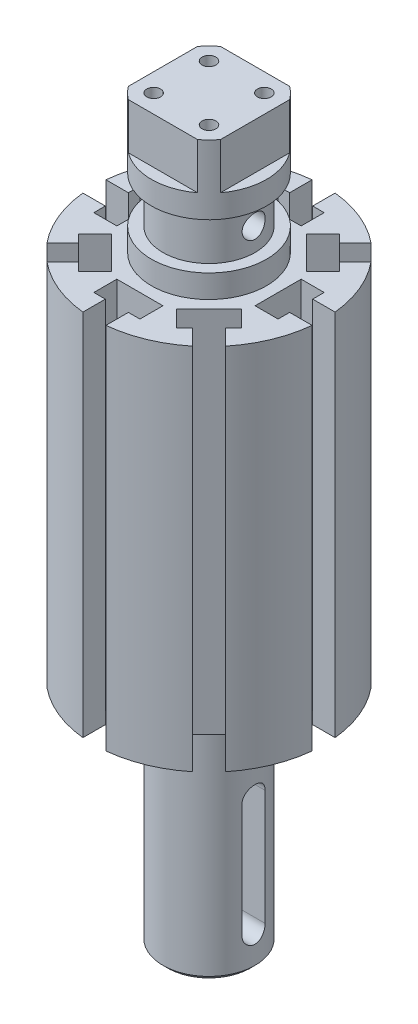
from build123d import *

# Parameters (mm, degrees)
CHAMFER1_SIZE       = 1
CUT_EXTRUDE6_DEPTH  = 130
CIRPATTERN1_COUNT   = 8
CUT_EXTRUDE8_DEPTH  = 10
SKETCH4_R           = 1.5
CUT_EXTRUDE9_DEPTH  = 15
SKETCH5_R           = 2.5
CUT_EXTRUDE10_DEPTH = 20
CUT_EXTRUDE11_DEPTH = 20


with BuildPart() as part:
    # Sketch1 → Revolve8 (revolve)
    with BuildSketch(Plane.XY):
        Polygon((0, 0), (10, 0), (10, 50), (25, 50), (25, 130), (12.5, 130), (12.5, 135), (10, 135), (10, 145), (12.5, 145), (12.5, 160), (0, 160), align=None)
    revolve(axis=Axis((0, 0, 0), (0, 1, 0)))

    # Chamfer1
    chamfer1_edges = [part.edges().sort_by_distance(p)[0] for p in [
        (-10, 0, 0),
    ]]
    chamfer(chamfer1_edges, length=CHAMFER1_SIZE)

    # Sketch2 → Cut-Extrude6 (cut)
    with BuildSketch(Plane(origin=(0, 0, 0), x_dir=(1, 0, 0), z_dir=(0, 1, 0))):
        with BuildLine():
            Line((24.874685928, 2.5), (20, 2.5))
            Line((20, 2.5), (20, 5))
            Line((20, 5), (15, 5))
            Line((15, 5), (15, -5))
            Line((15, -5), (20, -5))
            Line((20, -5), (20, -2.5))
            Line((20, -2.5), (24.874685928, -2.5))
            ThreePointArc((24.874685928, -2.5), (25, 0), (24.874685928, 2.5))
        make_face()
    cut_extrude6 = extrude(amount=CUT_EXTRUDE6_DEPTH, mode=Mode.SUBTRACT)

    # CirPattern1: Cut-Extrude6 ×8 about axis
    cirpattern1_axis = Axis((0, 0, 0), (0, 1, 0))
    for i in range(1, CIRPATTERN1_COUNT):
        add(cut_extrude6.rotate(cirpattern1_axis, i * 360 / CIRPATTERN1_COUNT), mode=Mode.SUBTRACT)

    # Sketch3 → Cut-Extrude8 (cut)
    with BuildSketch(Plane(origin=(0, 160, 0), x_dir=(1, 0, 0), z_dir=(0, 1, 0))):
        with BuildLine():
            Line((-7.5, 10), (7.5, 10))
            ThreePointArc((7.5, 10), (0, 12.5), (-7.5, 10))
        make_face()
        with BuildLine():
            Line((-10, 7.5), (-10, -7.5))
            ThreePointArc((-10, -7.5), (-12.5, 0), (-10, 7.5))
        make_face()
        with BuildLine():
            Line((-7.5, -10), (7.5, -10))
            ThreePointArc((7.5, -10), (0, -12.5), (-7.5, -10))
        make_face()
        with BuildLine():
            Line((10, 7.5), (10, -7.5))
            ThreePointArc((10, -7.5), (12.5, 0), (10, 7.5))
        make_face()
    extrude(amount=-CUT_EXTRUDE8_DEPTH, mode=Mode.SUBTRACT)

    # Sketch4 → Cut-Extrude9 (cut)
    with BuildSketch(Plane(origin=(0, 160, 0), x_dir=(1, 0, 0), z_dir=(0, 1, 0))):
        with Locations((-6, 6)):
            Circle(SKETCH4_R)
        with Locations((6, 6)):
            Circle(SKETCH4_R)
        with Locations((6, -6)):
            Circle(SKETCH4_R)
        with Locations((-6, -6)):
            Circle(SKETCH4_R)
    extrude(amount=-CUT_EXTRUDE9_DEPTH, mode=Mode.SUBTRACT)

    # Sketch5 → Cut-Extrude10 (cut)
    with BuildSketch(Plane.ZY.offset(10)):
        with Locations((0, 140)):
            Circle(SKETCH5_R)
    extrude(amount=-CUT_EXTRUDE10_DEPTH, mode=Mode.SUBTRACT)

    # Sketch6 → Cut-Extrude11 (cut)
    with BuildSketch(Plane.ZY.offset(10)):
        with BuildLine():
            Line((2.5, 32.5), (2.5, 7.5))
            ThreePointArc((2.5, 7.5), (0, 5), (-2.5, 7.5))
            Line((-2.5, 7.5), (-2.5, 32.5))
            ThreePointArc((-2.5, 32.5), (0, 35), (2.5, 32.5))
        make_face()
    extrude(amount=-CUT_EXTRUDE11_DEPTH, mode=Mode.SUBTRACT)


solid = part.part
